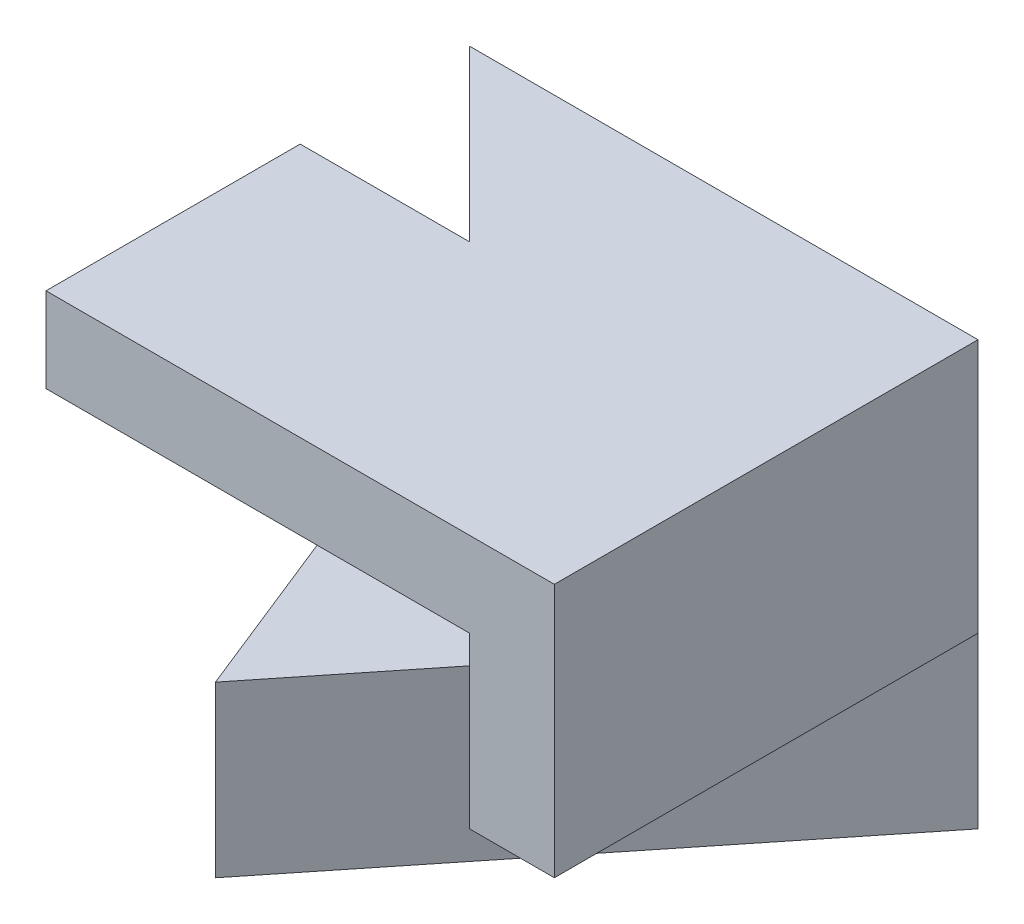
from build123d import *

# Parameters (mm, degrees)
SKETCH3_W           = 6
SKETCH3_H           = 5
BOSS_EXTRUDE1_DEPTH = 5
CUT_EXTRUDE1_DEPTH  = 3
CUT_EXTRUDE2_DEPTH  = 3
SKETCH6_W           = 3
SKETCH6_H           = 1
BOSS_EXTRUDE2_DEPTH = 6
CUT_EXTRUDE3_DEPTH  = 2


with BuildPart() as part:
    # Sketch3 → Boss-Extrude1 (new body)
    with BuildSketch(Plane.XY):
        with Locations((3, 2.5)):
            Rectangle(SKETCH3_W, SKETCH3_H)
    extrude(amount=BOSS_EXTRUDE1_DEPTH)

    # Sketch4 → Cut-Extrude1 (cut)
    with BuildSketch(Plane(origin=(0, 5, 0), x_dir=(1, 0, 0), z_dir=(0, 1, 0))):
        Polygon((0, 0), (5, -5), (0, -5), align=None)
    extrude(amount=-CUT_EXTRUDE1_DEPTH, mode=Mode.SUBTRACT)

    # Sketch5 → Cut-Extrude2 (cut)
    with BuildSketch(Plane(origin=(0, 2, 0), x_dir=(1, 0, 0), z_dir=(0, 1, 0))):
        Polygon((0, 0), (2, -5), (0, -5), align=None)
    extrude(amount=-CUT_EXTRUDE2_DEPTH, mode=Mode.SUBTRACT)

    # Sketch6 → Boss-Extrude2 (add)
    with BuildSketch(Plane(origin=(6, 0, 0), x_dir=(0, 0, -1), z_dir=(1, 0, 0))):
        with Locations((-3.5, 4.5)):
            Rectangle(SKETCH6_W, SKETCH6_H)
    extrude(amount=-BOSS_EXTRUDE2_DEPTH)

    # Sketch7 → Cut-Extrude3 (cut)
    with BuildSketch(Plane.XZ):
        Polygon((2, 5), (6, 0), (6, 5), align=None)
    extrude(amount=-CUT_EXTRUDE3_DEPTH, mode=Mode.SUBTRACT)


solid = part.part
